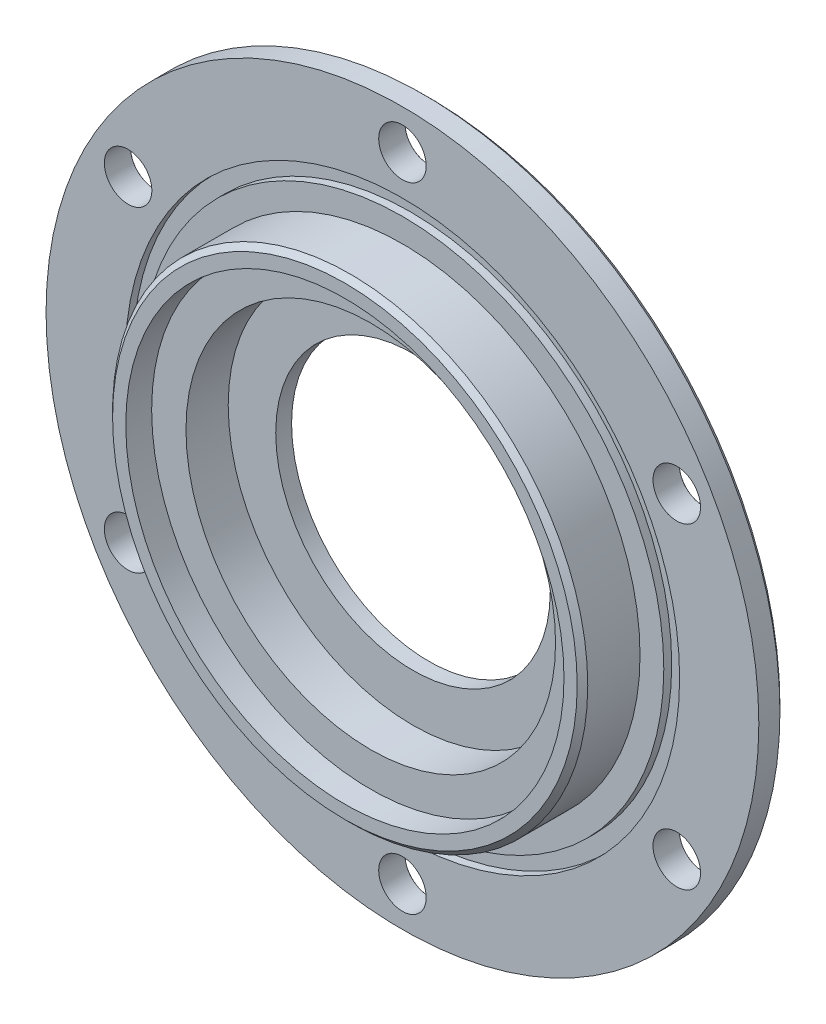
from build123d import *

# Parameters (mm, degrees)
SCHIZZO2_R                     = 67.5
ESTRUSIONE_ESTRUSIONE1_DEPTH   = 5
SCHIZZO3_R                     = 45
ESTRUSIONE_ESTRUSIONE2_DEPTH   = 6
SCHIZZO4_R                     = 26
TAGLIO_ESTRUSIONE1_DEPTH       = 3
SCHIZZO5_R                     = 35
TAGLIO_ESTRUSIONE2_DEPTH       = 9
SMUSSO1_SIZE                   = 1
FORO_PER_VITE_M8_1_D           = 9
FORO_PER_VITE_M8_1_CSINK_D     = 9.05
FORO_PER_VITE_M8_1_CSINK_ANGLE = 90
RIPETIZIONECIRCOLARE1_COUNT    = 6
SCHIZZO9_R                     = 52.5
SCHIZZO9_R_2                   = 49.5
TAGLIO_ESTRUSIONE3_DEPTH       = 1.5
SCHIZZO10_R                    = 45
SCHIZZO10_R_2                  = 41.5
ESTRUSIONE_ESTRUSIONE3_DEPTH   = 4.9
SMUSSO2_SIZE                   = 1


with BuildPart() as part:
    # Schizzo2 → Estrusione-Estrusione1 (new body)
    with BuildSketch(Plane.XY):
        Circle(SCHIZZO2_R)
    extrude(amount=ESTRUSIONE_ESTRUSIONE1_DEPTH)

    # Schizzo3 → Estrusione-Estrusione2 (add)
    with BuildSketch(Plane.XY.offset(5)):
        Circle(SCHIZZO3_R)
    extrude(amount=ESTRUSIONE_ESTRUSIONE2_DEPTH)

    # Schizzo4 → Taglio-Estrusione1 (cut)
    with BuildSketch(Plane(origin=(0, 0, 0), x_dir=(-1, 0, 0), z_dir=(0, 0, -1))):
        Circle(SCHIZZO4_R)
    extrude(amount=-TAGLIO_ESTRUSIONE1_DEPTH, mode=Mode.SUBTRACT)

    # Schizzo5 → Taglio-Estrusione2 (cut, through all)
    with BuildSketch(Plane(origin=(0, 0, 3), x_dir=(-1, 0, 0), z_dir=(0, 0, -1))):
        Circle(SCHIZZO5_R)
    extrude(amount=-TAGLIO_ESTRUSIONE2_DEPTH, mode=Mode.SUBTRACT)

    # Smusso1
    smusso1_edges = [part.edges().sort_by_distance(p)[0] for p in [
        (-67.5, 0, 0),
    ]]
    chamfer(smusso1_edges, length=SMUSSO1_SIZE)

    # Foro per Vite M8-1 (through all)
    with Locations(Plane(origin=(0, 0, 0), x_dir=(-1, 0, 0), z_dir=(0, 0, -1))):
        with Locations((0, 60)):
            foro_per_vite_m8_1 = CounterSinkHole(FORO_PER_VITE_M8_1_D / 2, FORO_PER_VITE_M8_1_CSINK_D / 2, counter_sink_angle=FORO_PER_VITE_M8_1_CSINK_ANGLE)

    # RipetizioneCircolare1: Foro per Vite M8-1 ×6 about axis
    ripetizionecircolare1_axis = Axis((0, 0, 0), (0, 0, 1))
    for i in range(1, RIPETIZIONECIRCOLARE1_COUNT):
        add(foro_per_vite_m8_1.rotate(ripetizionecircolare1_axis, i * 360 / RIPETIZIONECIRCOLARE1_COUNT), mode=Mode.SUBTRACT)

    # Schizzo9 → Taglio-Estrusione3 (cut)
    with BuildSketch(Plane.XY.offset(5)):
        Circle(SCHIZZO9_R)
        Circle(SCHIZZO9_R_2, mode=Mode.SUBTRACT)
    extrude(amount=-TAGLIO_ESTRUSIONE3_DEPTH, mode=Mode.SUBTRACT)

    # Schizzo10 → Estrusione-Estrusione3 (add)
    with BuildSketch(Plane.XY.offset(11)):
        Circle(SCHIZZO10_R)
        Circle(SCHIZZO10_R_2, mode=Mode.SUBTRACT)
    extrude(amount=ESTRUSIONE_ESTRUSIONE3_DEPTH)

    # Smusso2
    smusso2_edges = [part.edges().sort_by_distance(p)[0] for p in [
        (-45, 0, 15.9),
    ]]
    chamfer(smusso2_edges, length=SMUSSO2_SIZE)


solid = part.part
